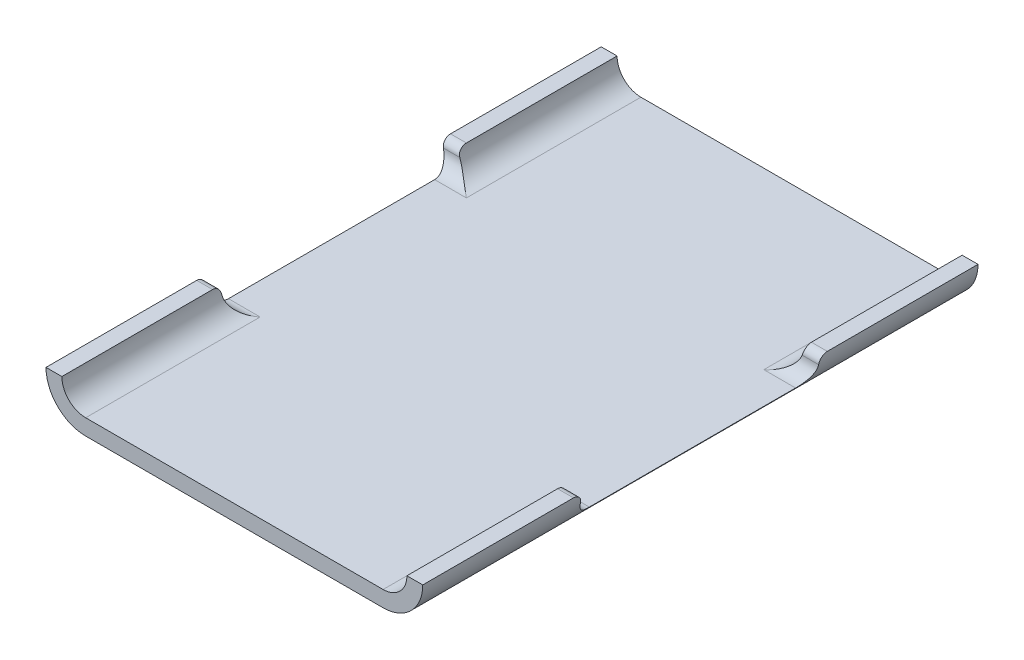
from build123d import *

# Parameters (mm, degrees)
SKETCH2_W           = 47.5
SKETCH2_H           = 70
BOSS_EXTRUDE1_DEPTH = 5
CUT_EXTRUDE2_DEPTH  = 48.5
CUT_EXTRUDE1_DEPTH  = 71
CUT_EXTRUDE3_DEPTH  = 0.5
BOSS_EXTRUDE2_DEPTH = 14
CHAMFER1_SIZE       = 1


with BuildPart() as part:
    # Sketch2 → Boss-Extrude1 (new body)
    with BuildSketch(Plane(origin=(0, 0, 0), x_dir=(1, 0, 0), z_dir=(0, 1, 0))):
        with Locations((23.75, -35)):
            Rectangle(SKETCH2_W, SKETCH2_H)
    extrude(amount=BOSS_EXTRUDE1_DEPTH)

    # Sketch4 → Cut-Extrude2 (cut, through all)
    with BuildSketch(Plane.ZY):
        with BuildLine():
            Line((19, 5), (51, 5))
            ThreePointArc((51, 5), (50.292893219, 4.707106781), (50, 4))
            ThreePointArc((50, 4), (49.414213562, 2.585786438), (48, 2))
            Line((48, 2), (22, 2))
            ThreePointArc((22, 2), (20.585786438, 2.585786438), (20, 4))
            ThreePointArc((20, 4), (19.707106781, 4.707106781), (19, 5))
        make_face()
    extrude(amount=-CUT_EXTRUDE2_DEPTH, mode=Mode.SUBTRACT)

    # Sketch3 → Cut-Extrude1 (cut, through all)
    with BuildSketch(Plane.XY.offset(70)):
        with BuildLine():
            Line((5, 2), (42.5, 2))
            ThreePointArc((42.5, 2), (44.621320344, 2.878679656), (45.5, 5))
            Line((45.5, 5), (2, 5))
            ThreePointArc((2, 5), (2.878679656, 2.878679656), (5, 2))
        make_face()
        with BuildLine():
            Line((42.5, 0), (47.5, 0))
            Line((47.5, 0), (47.5, 5))
            ThreePointArc((47.5, 5), (46.035533906, 1.464466094), (42.5, 0))
        make_face()
        with BuildLine():
            Line((0, 5), (0, 0))
            Line((0, 0), (5, 0))
            ThreePointArc((5, 0), (1.464466094, 1.464466094), (0, 5))
        make_face()
    extrude(amount=-CUT_EXTRUDE1_DEPTH, mode=Mode.SUBTRACT)

    # Sketch6 → Cut-Extrude3 (cut)
    with BuildSketch(Plane.XZ):
        with BuildLine():
            Line((28.75, 35), (28.75, 42.5))
            ThreePointArc((28.75, 42.5), (23.75, 47.5), (18.75, 42.5))
            Line((18.75, 42.5), (18.75, 27.5))
            ThreePointArc((18.75, 27.5), (23.75, 22.5), (28.75, 27.5))
            Line((28.75, 27.5), (28.75, 35))
        make_face()
    extrude(amount=-CUT_EXTRUDE3_DEPTH, mode=Mode.SUBTRACT)


with BuildPart() as body_2:
    # Sketch5 → Boss-Extrude2 (new body)
    with BuildSketch(Plane.XZ):
        with BuildLine():
            Line((21.25, 40.482011201), (21.25, 35.982011201))
            Line((21.25, 35.982011201), (19.75, 35.982011201))
            Line((19.75, 35.982011201), (19.75, 33.982011201))
            Line((19.75, 33.982011201), (21.25, 33.982011201))
            Line((21.25, 33.982011201), (21.25, 29.482011201))
            Line((21.25, 29.482011201), (19.75, 29.482011201))
            Line((19.75, 29.482011201), (19.75, 27.482011201))
            Line((19.75, 27.482011201), (21.25, 27.482011201))
            ThreePointArc((21.25, 27.482011201), (23.75, 24.982011201), (26.25, 27.482011201))
            Line((26.25, 27.482011201), (27.75, 27.482011201))
            Line((27.75, 27.482011201), (27.75, 29.482011201))
            Line((27.75, 29.482011201), (26.25, 29.482011201))
            Line((26.25, 29.482011201), (26.25, 33.982011201))
            Line((26.25, 33.982011201), (27.75, 33.982011201))
            Line((27.75, 33.982011201), (27.75, 35.982011201))
            Line((27.75, 35.982011201), (26.25, 35.982011201))
            Line((26.25, 35.982011201), (26.25, 40.482011201))
            Line((26.25, 40.482011201), (27.75, 40.482011201))
            Line((27.75, 40.482011201), (27.75, 42.482011201))
            Line((27.75, 42.482011201), (26.25, 42.482011201))
            ThreePointArc((26.25, 42.482011201), (23.75, 44.982011201), (21.25, 42.482011201))
            Line((21.25, 42.482011201), (19.75, 42.482011201))
            Line((19.75, 42.482011201), (19.75, 40.482011201))
            Line((19.75, 40.482011201), (21.25, 40.482011201))
        make_face()
    extrude(amount=BOSS_EXTRUDE2_DEPTH)

    # Chamfer1
    chamfer1_edges = [body_2.edges().sort_by_distance(p)[0] for p in [
        (19.75, -14, 34.982011201),
        (19.75, -14, 28.482011201),
        (27.75, -14, 28.482011201),
        (27.75, -14, 34.982011201),
        (27.75, -14, 41.482011201),
        (19.75, -14, 41.482011201),
    ]]
    chamfer(chamfer1_edges, length=CHAMFER1_SIZE)


solid = Compound([part.part, body_2.part])
